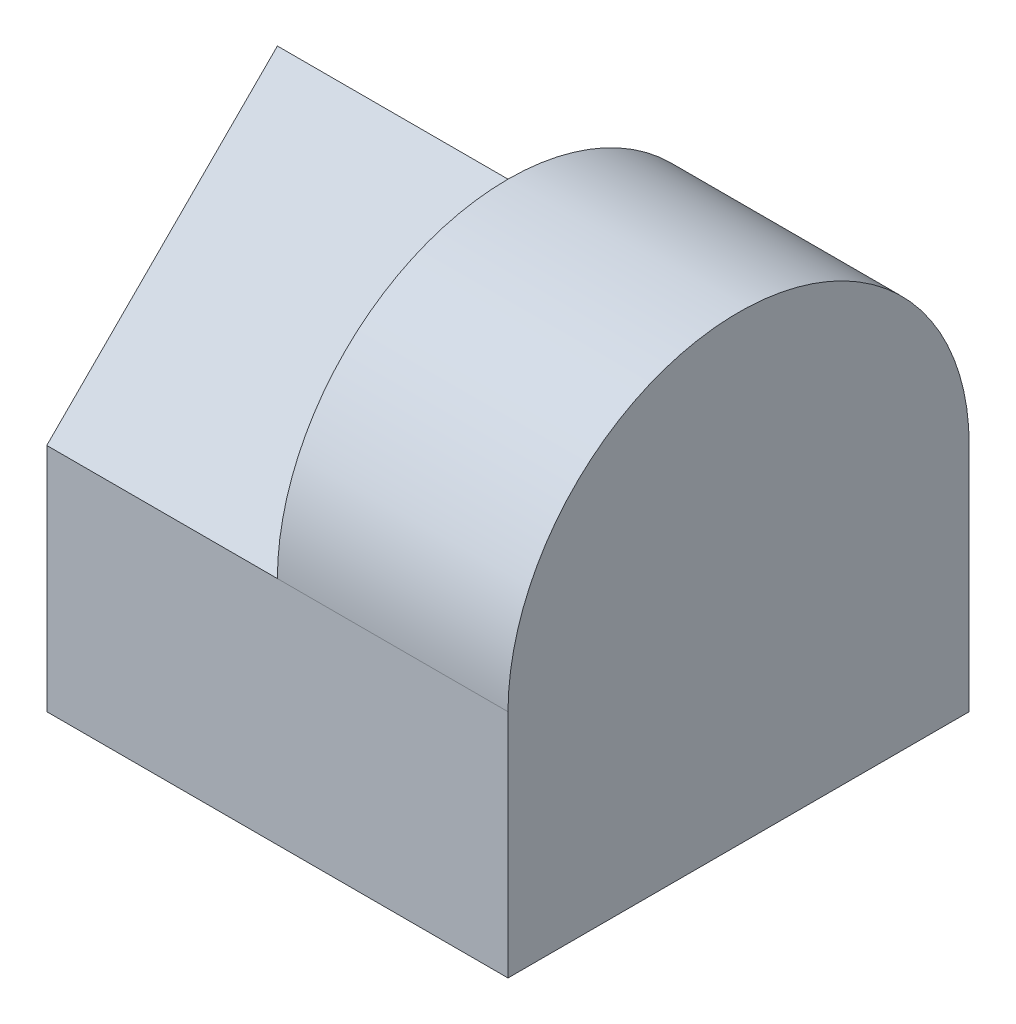
from build123d import *

# Parameters (mm, degrees)
SKETCH1_W           = 4
SKETCH1_H           = 4
BOSS_EXTRUDE1_DEPTH = 4
CUT_EXTRUDE1_DEPTH  = 2
CUT_EXTRUDE2_DEPTH  = 10


with BuildPart() as part:
    # Sketch1 → Boss-Extrude1 (new body)
    with BuildSketch(Plane(origin=(0, 0, 0), x_dir=(1, 0, 0), z_dir=(0, 1, 0))):
        Rectangle(SKETCH1_W, SKETCH1_H)
    extrude(amount=BOSS_EXTRUDE1_DEPTH)

    # Sketch2 → Cut-Extrude1 (cut)
    with BuildSketch(Plane.ZY.offset(2)):
        Polygon((-2, 2), (0, 4), (-2, 4), align=None)
        Polygon((0, 4), (2, 2), (2, 4), align=None)
    extrude(amount=-CUT_EXTRUDE1_DEPTH, mode=Mode.SUBTRACT)

    # Sketch3 → Cut-Extrude2 (cut)
    with BuildSketch(Plane.ZY):
        with BuildLine():
            ThreePointArc((-2, 2), (-1.414213562, 3.414213562), (0, 4))
            Line((0, 4), (-2, 4))
            Line((-2, 4), (-2, 2))
        make_face()
        with BuildLine():
            Line((2, 4), (0, 4))
            ThreePointArc((0, 4), (1.414213562, 3.414213562), (2, 2))
            Line((2, 2), (2, 4))
        make_face()
    extrude(amount=-CUT_EXTRUDE2_DEPTH, mode=Mode.SUBTRACT)


solid = part.part
